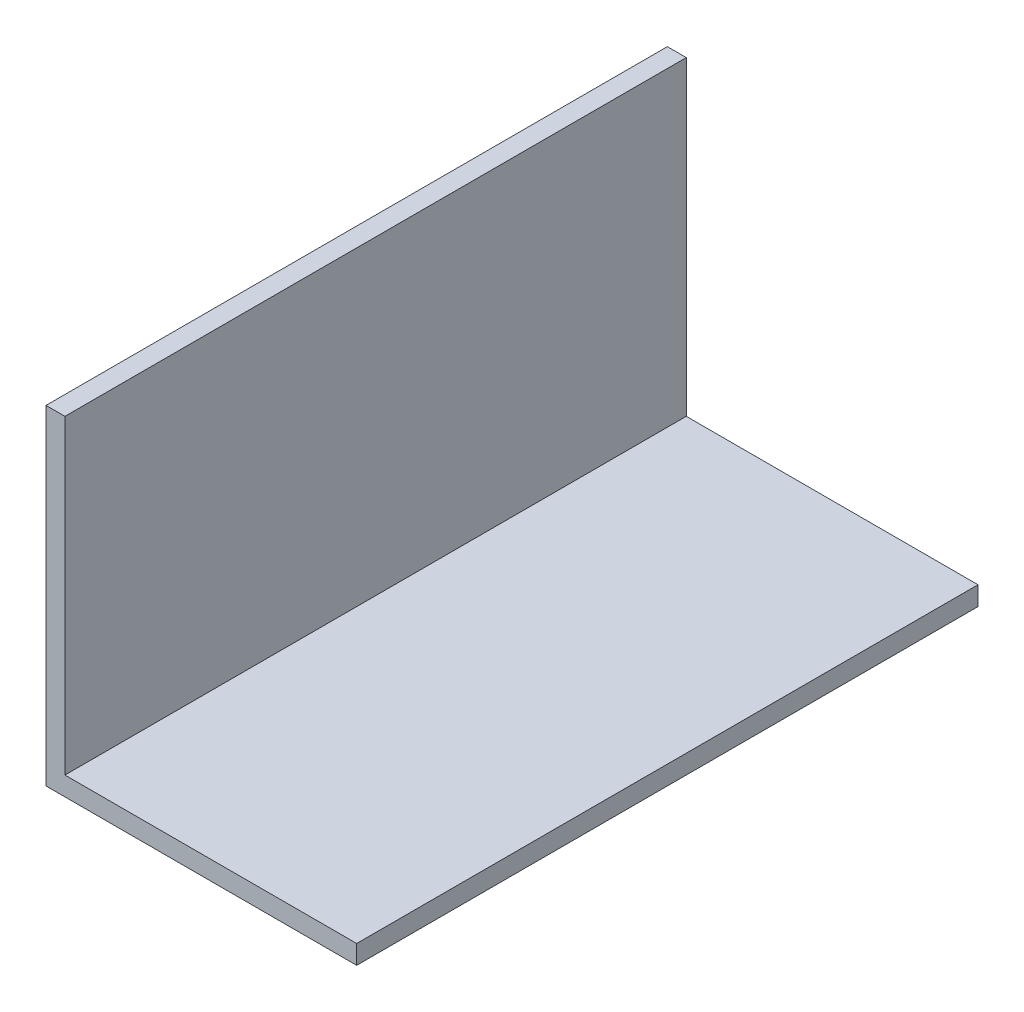
from build123d import *

# Parameters (mm, degrees)
BOSS_EXTRUDE1_DEPTH      = 4999.99999998
BOSS_EXTRUDE1_DEPTH_BACK = 4999.99


with BuildPart() as part:
    # wall → Boss-Extrude1 (new body, two sides)
    with BuildSketch(Plane.XY) as boss_extrude1_sk:
        Polygon((0, 0), (0, 5304.79999998), (304.8, 5304.79999998), (304.8, 304.8), (4999.99999998, 304.8), (4999.99999998, 0), align=None)
    extrude(amount=BOSS_EXTRUDE1_DEPTH)
    extrude(boss_extrude1_sk.sketch, amount=-BOSS_EXTRUDE1_DEPTH_BACK)


solid = part.part
